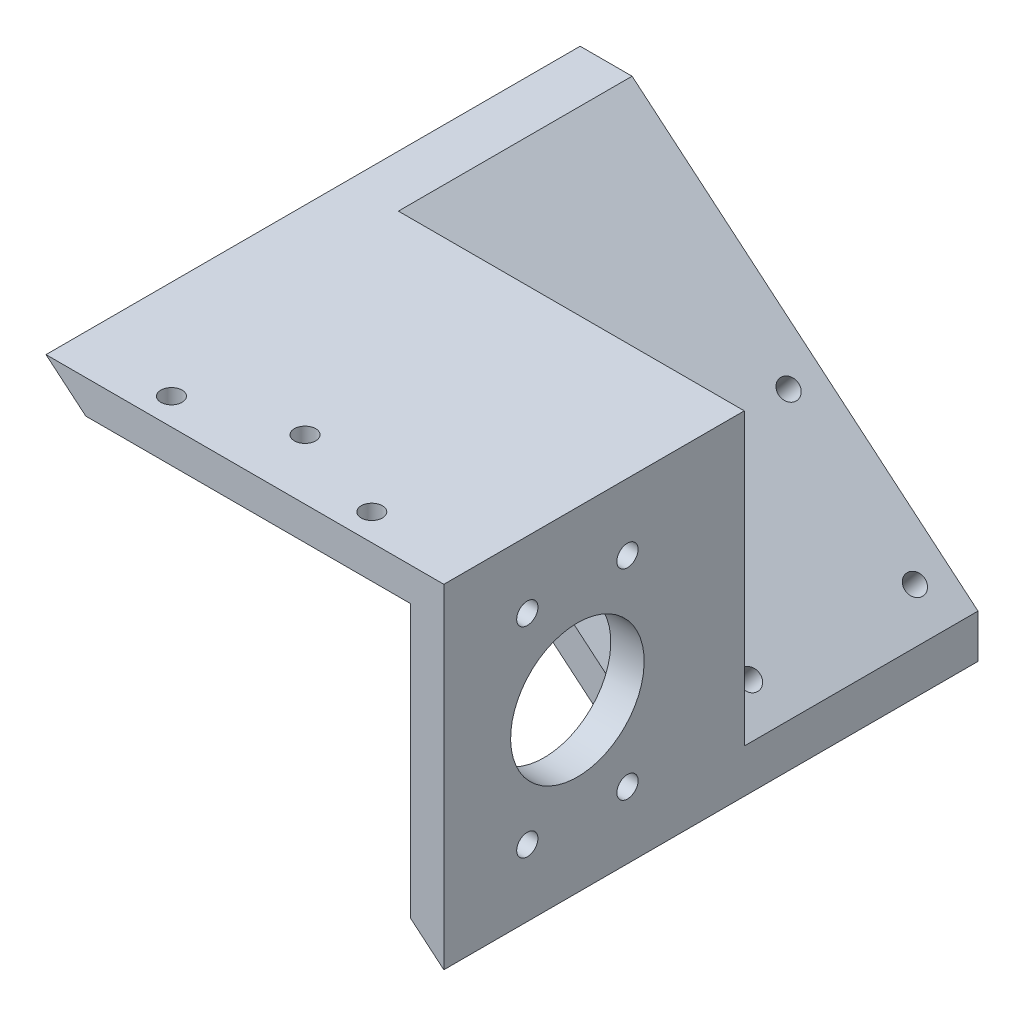
from build123d import *

# Parameters (mm, degrees)
BOSS_EXTRUDE1_DEPTH        = 101.6
CUT_EXTRUDE2_START         = -6.35
SKETCH3_W                  = 69.32635313
SKETCH3_H                  = 44.45
CUT_EXTRUDE2_DEPTH         = 58.15
CUT_EXTRUDE3_REACH         = 77.676
SKETCH4_R                  = 12.7
F_10_32_TAPPED_HOLE1_D     = 4.0386
F_10_32_TAPPED_HOLE1_DEPTH = 6.35
F_10_32_TAPPED_HOLE2_D     = 4.0386
F_10_32_TAPPED_HOLE2_DEPTH = 6.35
CUT_EXTRUDE4_DEPTH         = 44.45
CUT_EXTRUDE5_REACH         = 50.644
SKETCH11_R                 = 1.905


with BuildPart() as part:
    # Sketch1 → Boss-Extrude1 (new body)
    with BuildSketch(Plane.XY):
        Polygon((0, 0), (75.67635313, 0), (75.67635313, -63.5), align=None)
        Polygon((17.446481614, -6.35), (69.32635313, -6.35), (69.32635313, -49.882381055), align=None, mode=Mode.SUBTRACT)
    extrude(amount=BOSS_EXTRUDE1_DEPTH)

    # Sketch3 → Cut-Extrude2 (cut, through all)
    with BuildSketch(Plane(origin=(0, 0, 0), x_dir=(1, 0, 0), z_dir=(0, 1, 0)).offset(CUT_EXTRUDE2_START)):
        with Locations((34.663176565, -79.375)):
            Rectangle(SKETCH3_W, SKETCH3_H)
    extrude(amount=-CUT_EXTRUDE2_DEPTH, mode=Mode.SUBTRACT)

    # Sketch4 → Cut-Extrude3 (cut, up to next)
    with BuildSketch(Plane(origin=(75.67635313, 0, 0), x_dir=(0, 0, -1), z_dir=(1, 0, 0)), mode=Mode.PRIVATE) as cut_extrude3_sk1:
        with Locations((-76.2, -31.75)):
            Circle(SKETCH4_R)
    cut_extrude3_tool1 = extrude(cut_extrude3_sk1.sketch, amount=-CUT_EXTRUDE3_REACH, mode=Mode.PRIVATE) & part.part
    add(cut_extrude3_tool1.solids().sort_by_distance((75.676353, -31.75, 76.2))[0], mode=Mode.SUBTRACT)

    # #10-32 Tapped Hole1
    with Locations(Plane(origin=(75.67635313, -50.8, 85.725), x_dir=(0, 1, 0), z_dir=(1, 0, 0))):
        with Locations((0, 0), (0, -19.05), (38.1, 0), (38.1, -19.05)):
            Hole(F_10_32_TAPPED_HOLE1_D / 2, depth=F_10_32_TAPPED_HOLE1_DEPTH)

    # #10-32 Tapped Hole2
    with Locations(Plane(origin=(0, 0, 0), x_dir=(1, 0, 0), z_dir=(0, 1, 0))):
        with Locations((56.888176565, -96.52), (37.838176565, -90.17), (18.788176565, -96.52)):
            Hole(F_10_32_TAPPED_HOLE2_D / 2, depth=F_10_32_TAPPED_HOLE2_DEPTH)

    # Sketch10 → Cut-Extrude4 (cut)
    with BuildSketch(Plane(origin=(0, 0, 0), x_dir=(-1, 0, 0), z_dir=(0, 0, -1))):
        Polygon((-75.67635313, -55.210663713), (-9.878846301, 0), (-75.67635313, 0), align=None)
    extrude(amount=-CUT_EXTRUDE4_DEPTH, mode=Mode.SUBTRACT)

    # Sketch11 → Cut-Extrude5 (cut, up to next)
    with BuildSketch(Plane(origin=(0, 0, 0), x_dir=(0.766044443, -0.64278761, 0), z_dir=(-0.64278761, -0.766044443, 0)), mode=Mode.PRIVATE) as cut_extrude5_sk1:
        with Locations((54.719463006, 37.719)):
            Circle(SKETCH11_R)
    cut_extrude5_tool1 = extrude(cut_extrude5_sk1.sketch, amount=-CUT_EXTRUDE5_REACH, mode=Mode.PRIVATE) & part.part
    add(cut_extrude5_tool1.solids().sort_by_distance((41.917541, -35.172993, 37.719))[0], mode=Mode.SUBTRACT)
    # Sketch11 → Cut-Extrude5 (cut, up to next)
    with BuildSketch(Plane(origin=(0, 0, 0), x_dir=(0.766044443, -0.64278761, 0), z_dir=(-0.64278761, -0.766044443, 0)), mode=Mode.PRIVATE) as cut_extrude5_sk2:
        with Locations((86.088463006, 37.719)):
            Circle(SKETCH11_R)
    cut_extrude5_tool2 = extrude(cut_extrude5_sk2.sketch, amount=-CUT_EXTRUDE5_REACH, mode=Mode.PRIVATE) & part.part
    add(cut_extrude5_tool2.solids().sort_by_distance((65.947589, -55.336597, 37.719))[0], mode=Mode.SUBTRACT)
    # Sketch11 → Cut-Extrude5 (cut, up to next)
    with BuildSketch(Plane(origin=(0, 0, 0), x_dir=(0.766044443, -0.64278761, 0), z_dir=(-0.64278761, -0.766044443, 0)), mode=Mode.PRIVATE) as cut_extrude5_sk3:
        with Locations((54.719463006, 6.35)):
            Circle(SKETCH11_R)
    cut_extrude5_tool3 = extrude(cut_extrude5_sk3.sketch, amount=-CUT_EXTRUDE5_REACH, mode=Mode.PRIVATE) & part.part
    add(cut_extrude5_tool3.solids().sort_by_distance((41.917541, -35.172993, 6.35))[0], mode=Mode.SUBTRACT)
    # Sketch11 → Cut-Extrude5 (cut, up to next)
    with BuildSketch(Plane(origin=(0, 0, 0), x_dir=(0.766044443, -0.64278761, 0), z_dir=(-0.64278761, -0.766044443, 0)), mode=Mode.PRIVATE) as cut_extrude5_sk4:
        with Locations((86.088463006, 6.35)):
            Circle(SKETCH11_R)
    cut_extrude5_tool4 = extrude(cut_extrude5_sk4.sketch, amount=-CUT_EXTRUDE5_REACH, mode=Mode.PRIVATE) & part.part
    add(cut_extrude5_tool4.solids().sort_by_distance((65.947589, -55.336597, 6.35))[0], mode=Mode.SUBTRACT)


solid = part.part
